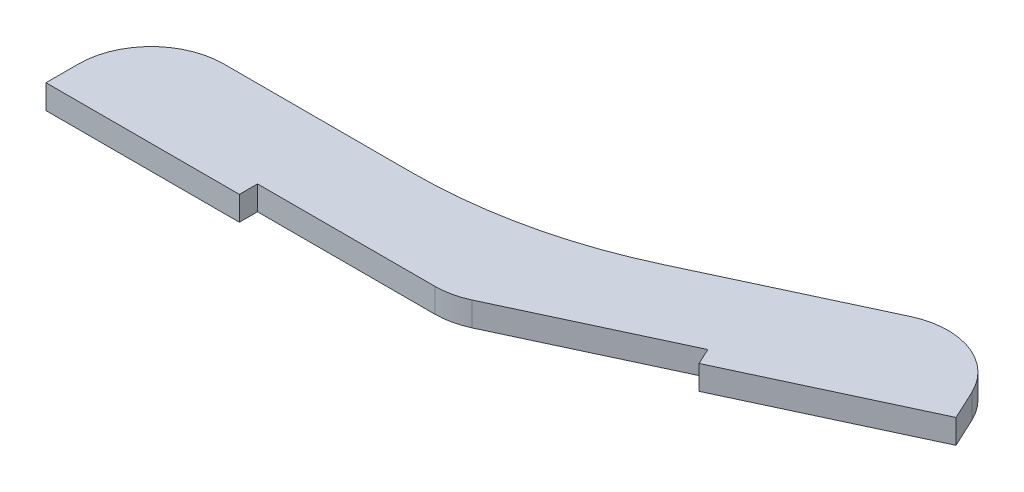
from build123d import *

# Parameters (mm, degrees)
BOSS_EXTRUDE1_DEPTH = 3.175
SKETCH2_W           = 25.4
SKETCH2_H           = 2.38125
BOSS_EXTRUDE2_DEPTH = 3.175
CUT_EXTRUDE1_DEPTH  = 4.175
FILLET1_R           = 9.525
FILLET2_R           = 63.5


with BuildPart() as part:
    # Sketch1 → Boss-Extrude1 (new body)
    with BuildSketch(Plane(origin=(0, 0, 0), x_dir=(1, 0, 0), z_dir=(0, 1, 0))):
        Polygon((-50.8, 0), (0, 0), (46.040435581, 21.469007696), (40.673183657, 32.979116592), (-50.8, 12.7), align=None)
    extrude(amount=BOSS_EXTRUDE1_DEPTH)

    # Sketch2 → Boss-Extrude2 (add)
    with BuildSketch(Plane(origin=(0, 3.175, 0), x_dir=(1, 0, 0), z_dir=(0, 1, 0))):
        Polygon((23.020217791, 10.734503848), (46.040435581, 21.469007696), (47.046795317, 19.310862279), (24.026577527, 8.57635843), align=None)
        with Locations((-38.1, -1.190625)):
            Rectangle(SKETCH2_W, SKETCH2_H)
    extrude(amount=-BOSS_EXTRUDE2_DEPTH)

    # Sketch3 → Cut-Extrude1 (cut, through all)
    with BuildSketch(Plane(origin=(0, 3.175, 0), x_dir=(1, 0, 0), z_dir=(0, 1, 0))):
        Polygon((-25.4, 11.43), (-50.8, 11.43), (-50.8, 12.7), (40.673183657, 32.979116592), (41.20990885, 31.828105702), (18.189691059, 21.093601854), (-2.533969994, 11.43), align=None)
    extrude(amount=-CUT_EXTRUDE1_DEPTH, mode=Mode.SUBTRACT)

    # Fillet1
    fillet1_edges = [part.edges().sort_by_distance(p)[0] for p in [
        (0, 1.5875, 0),
        (41.20990885, 1.5875, -31.828105702),
        (-50.8, 1.5875, -11.43),
    ]]
    fillet(fillet1_edges, radius=FILLET1_R)

    # Fillet2
    fillet2_edges = [part.edges().sort_by_distance(p)[0] for p in [
        (-2.533969994, 1.5875, -11.43),
    ]]
    fillet(fillet2_edges, radius=FILLET2_R)


solid = part.part
